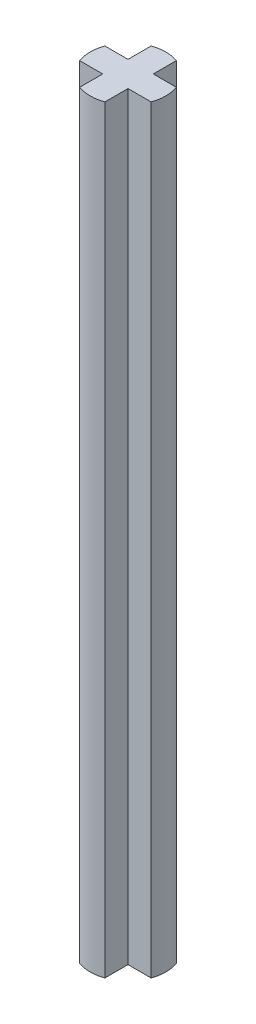
from build123d import *

# Parameters (mm, degrees)
SKETCH1_W           = 3
SKETCH1_H           = 1
SKETCH1_W_2         = 1
SKETCH1_H_2         = 3
BOSS_EXTRUDE1_DEPTH = 30
SKETCH2_OUTSIDE_W   = 11.06
SKETCH2_OUTSIDE_H   = 11.06
SKETCH2_OUTSIDE_R   = 1.5
CUT_EXTRUDE1_DEPTH  = 30


with BuildPart() as part:
    # Sketch1 → Boss-Extrude1 (new body)
    with BuildSketch(Plane(origin=(0, 0, 0), x_dir=(1, 0, 0), z_dir=(0, 1, 0))):
        Rectangle(SKETCH1_W, SKETCH1_H)
        Rectangle(SKETCH1_W_2, SKETCH1_H_2)
    extrude(amount=BOSS_EXTRUDE1_DEPTH)

    # Sketch2 outside → Cut-Extrude1 (cut)
    with BuildSketch(Plane(origin=(0, 30, 0), x_dir=(1, 0, 0), z_dir=(0, 1, 0))):
        Rectangle(SKETCH2_OUTSIDE_W, SKETCH2_OUTSIDE_H)
        Circle(SKETCH2_OUTSIDE_R, mode=Mode.SUBTRACT)
    extrude(amount=-CUT_EXTRUDE1_DEPTH, mode=Mode.SUBTRACT)


solid = part.part
